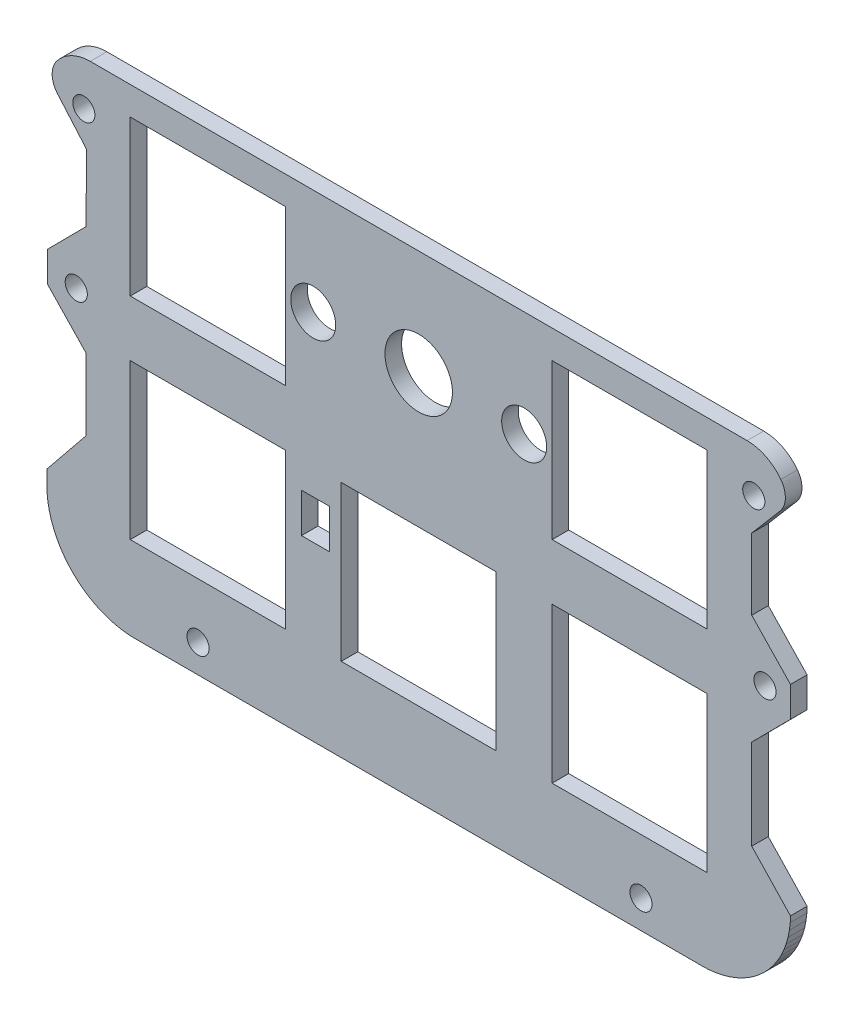
from build123d import *

# Parameters (mm, degrees)
MODEL_R         = 1
MODEL_W         = 13.99947
MODEL_H         = 13.99944
MODEL_W_2       = 2.54
MODEL_H_2       = 3.556
MODEL_W_3       = 13.9994
MODEL_W_4       = 13.9993
MODEL_H_3       = 13.9993
MODEL_R_2       = 2.032
MODEL_R_3       = 3.048
EXTRUDE_1_DEPTH = 1.5


with BuildPart() as part:
    # Model → 凸台-拉伸1 (new body)
    with BuildSketch(Plane.XY):
        with BuildLine():
            Line((58.325971896, 38.37894176), (-0.993511809, 38.37894176))
            ThreePointArc((-0.993511809, 38.37894176), (-2.684760262, 37.982445858), (-4.023562246, 36.875585623))
            ThreePointArc((-4.023562246, 36.875585623), (-4.429985557, 35.602098535), (-3.943386617, 34.357040005))
            Line((-3.943386617, 34.357040005), (-1.350000064, 31.36000149))
            Line((-1.350000064, 31.36000149), (-1.353515518, 25.280051374))
            Line((-1.353515518, 25.280051374), (-4.853428588, 21.752613865))
            Line((-4.853428588, 21.752613865), (-4.853710523, 19.020120221))
            Line((-4.853710523, 19.020120221), (-1.359258514, 15.363920359))
            Line((-1.359258514, 15.363920359), (-1.362991715, 8.917997305))
            Line((-1.362991715, 8.917997305), (-4.9049154, 4.538497879))
            Line((-4.9049154, 4.538497879), (-4.9049154, 3.15597541))
            Line((-4.9049154, 3.15597541), (-4.883883595, 2.639206616))
            Line((-4.883883595, 2.639206616), (-4.813264805, 2.011073476))
            Line((-4.813264805, 2.011073476), (-4.687062167, 1.387481119))
            Line((-4.687062167, 1.387481119), (-4.516803943, 0.776764684))
            Line((-4.516803943, 0.776764684), (-4.295659415, 0.187060206))
            Line((-4.295659415, 0.187060206), (-4.03681533, -0.378036856))
            Line((-4.03681533, -0.378036856), (-3.730362364, -0.921623746))
            Line((-3.730362364, -0.921623746), (-3.390574278, -1.434889052))
            Line((-3.390574278, -1.434889052), (-2.992281832, -1.942165148))
            Line((-2.992281832, -1.942165148), (-2.558331876, -2.409802006))
            Line((-2.558331876, -2.409802006), (-2.102251702, -2.829663369))
            Line((-2.102251702, -2.829663369), (-1.614610519, -3.215411153))
            Line((-1.614610519, -3.215411153), (-1.088890304, -3.567123565))
            Line((-1.088890304, -3.567123565), (-0.532800957, -3.878547051))
            Line((-0.532800957, -3.878547051), (0.038326794, -4.140153507))
            Line((0.038326794, -4.140153507), (0.615600502, -4.353028424))
            Line((0.615600502, -4.353028424), (1.223529929, -4.526191258))
            Line((1.223529929, -4.526191258), (1.847223482, -4.64943937))
            Line((1.847223482, -4.64943937), (2.464503115, -4.722060038))
            Line((2.464503115, -4.722060038), (2.992774524, -4.743685))
            Line((2.992774524, -4.743685), (54.34686609, -4.743685))
            Line((54.34686609, -4.743685), (54.87843401, -4.722059086))
            Line((54.87843401, -4.722059086), (55.492240411, -4.649391053))
            Line((55.492240411, -4.649391053), (56.11599848, -4.526806688))
            Line((56.11599848, -4.526806688), (56.726168878, -4.352867841))
            Line((56.726168878, -4.352867841), (57.302144081, -4.140491025))
            Line((57.302144081, -4.140491025), (57.880206411, -3.875955859))
            Line((57.880206411, -3.875955859), (58.434482529, -3.563431063))
            Line((58.434482529, -3.563431063), (58.947571314, -3.220379587))
            Line((58.947571314, -3.220379587), (59.445938304, -2.8287768))
            Line((59.445938304, -2.8287768), (59.905767444, -2.401934126))
            Line((59.905767444, -2.401934126), (60.332973054, -1.941418241))
            Line((60.332973054, -1.941418241), (60.721224007, -1.446690794))
            Line((60.721224007, -1.446690794), (61.064717919, -0.934798534))
            Line((61.064717919, -0.934798534), (61.379380282, -0.376374826))
            Line((61.379380282, -0.376374826), (61.644240363, 0.202684675))
            Line((61.644240363, 0.202684675), (61.855333273, 0.776565869))
            Line((61.855333273, 0.776565869), (62.029241049, 1.384922025))
            Line((62.029241049, 1.384922025), (62.152356641, 2.011350393))
            Line((62.152356641, 2.011350393), (62.226202972, 2.636734827))
            Line((62.226202972, 2.636734827), (62.245297192, 3.166071528))
            Line((62.245297192, 3.166071528), (58.745412398, 6.86443549))
            Line((58.745412398, 6.86443549), (58.745666056, 15.007268129))
            Line((58.745666056, 15.007268129), (62.245579127, 18.534705638))
            Line((62.245579127, 18.534705638), (62.245861062, 21.267199282))
            Line((62.245861062, 21.267199282), (58.745975132, 24.929084585))
            Line((58.745975132, 24.929084585), (58.746175407, 31.358234918))
            Line((58.746175407, 31.358234918), (61.304557204, 34.355344918))
            ThreePointArc((61.304557204, 34.355344918), (61.782522432, 35.594711806), (61.37863268, 36.860158015))
            ThreePointArc((61.37863268, 36.860158015), (60.030777011, 37.978272972), (58.325971896, 38.37894176))
        make_face()
        with Locations((8.744501265, -2.189788582)):
            Circle(MODEL_R, mode=Mode.SUBTRACT)
        with Locations((9.620765, 9.78198)):
            Rectangle(MODEL_W, MODEL_H, mode=Mode.SUBTRACT)
        with Locations((19.353985322, 12.60229784)):
            Rectangle(MODEL_W_2, MODEL_H_2, mode=Mode.SUBTRACT)
        with Locations((48.744501265, -2.189788582)):
            Circle(MODEL_R, mode=Mode.SUBTRACT)
        with Locations((28.6707, 9.78198)):
            Rectangle(MODEL_W_3, MODEL_H, mode=Mode.SUBTRACT)
        with Locations((47.72075, 9.78198)):
            Rectangle(MODEL_W_4, MODEL_H, mode=Mode.SUBTRACT)
        with Locations((-2.255498735, 20.010211418)):
            Circle(MODEL_R, mode=Mode.SUBTRACT)
        with Locations((9.620765, 28.83195)):
            Rectangle(MODEL_W, MODEL_H_3, mode=Mode.SUBTRACT)
        with Locations((-1.568763471, 34.380826193)):
            Circle(MODEL_R, mode=Mode.SUBTRACT)
        with Locations((19.1458, 28.832)):
            Circle(MODEL_R_2, mode=Mode.SUBTRACT)
        with Locations((59.944501265, 20.010211418)):
            Circle(MODEL_R, mode=Mode.SUBTRACT)
        with Locations((28.6708, 28.832)):
            Circle(MODEL_R_3, mode=Mode.SUBTRACT)
        with Locations((38.1958, 28.832)):
            Circle(MODEL_R_2, mode=Mode.SUBTRACT)
        with Locations((47.72075, 28.83195)):
            Rectangle(MODEL_W_4, MODEL_H_3, mode=Mode.SUBTRACT)
        with Locations((58.931236529, 34.380826193)):
            Circle(MODEL_R, mode=Mode.SUBTRACT)
    extrude(amount=EXTRUDE_1_DEPTH)


solid = part.part
